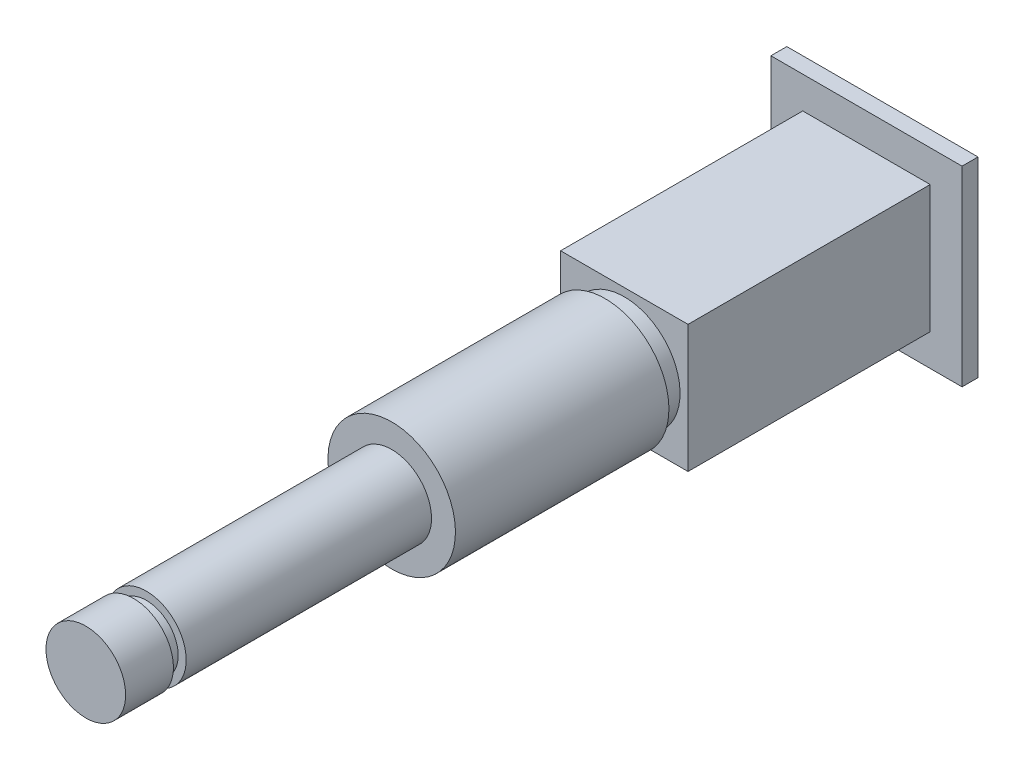
from build123d import *

# Parameters (mm, degrees)
SKETCH3_W           = 8
SKETCH3_H           = 8
BOSS_EXTRUDE2_DEPTH = 15.2
SKETCH4_W           = 12
SKETCH4_H           = 12
BOSS_EXTRUDE3_DEPTH = 1


with BuildPart() as part:
    # Sketch1 → Revolve1 (revolve)
    with BuildSketch(Plane(origin=(0, 0, 0), x_dir=(0, 0, -1), z_dir=(1, 0, 0))):
        Polygon((-19.2, 0), (30.8, 0), (30.8, 5), (29.8, 5), (29.8, 4), (14.6, 4), (14.6, 3.5), (13.4, 3.5), (13.4, 4), (0, 4), (0, 2.5), (-15.4, 2.5), (-15.4, 2), (-16.2, 2), (-16.2, 2.5), (-19.2, 2.5), align=None)
    revolve(axis=Axis((0, 0, 19.2), (0, 0, -1)))

    # Sketch3 → Boss-Extrude2 (add)
    with BuildSketch(Plane.XY.offset(-29.8)):
        Rectangle(SKETCH3_W, SKETCH3_H)
    extrude(amount=BOSS_EXTRUDE2_DEPTH)

    # Sketch4 → Boss-Extrude3 (add)
    with BuildSketch(Plane(origin=(0, 0, -30.8), x_dir=(-1, 0, 0), z_dir=(0, 0, -1))):
        Rectangle(SKETCH4_W, SKETCH4_H)
    extrude(amount=-BOSS_EXTRUDE3_DEPTH)


solid = part.part
